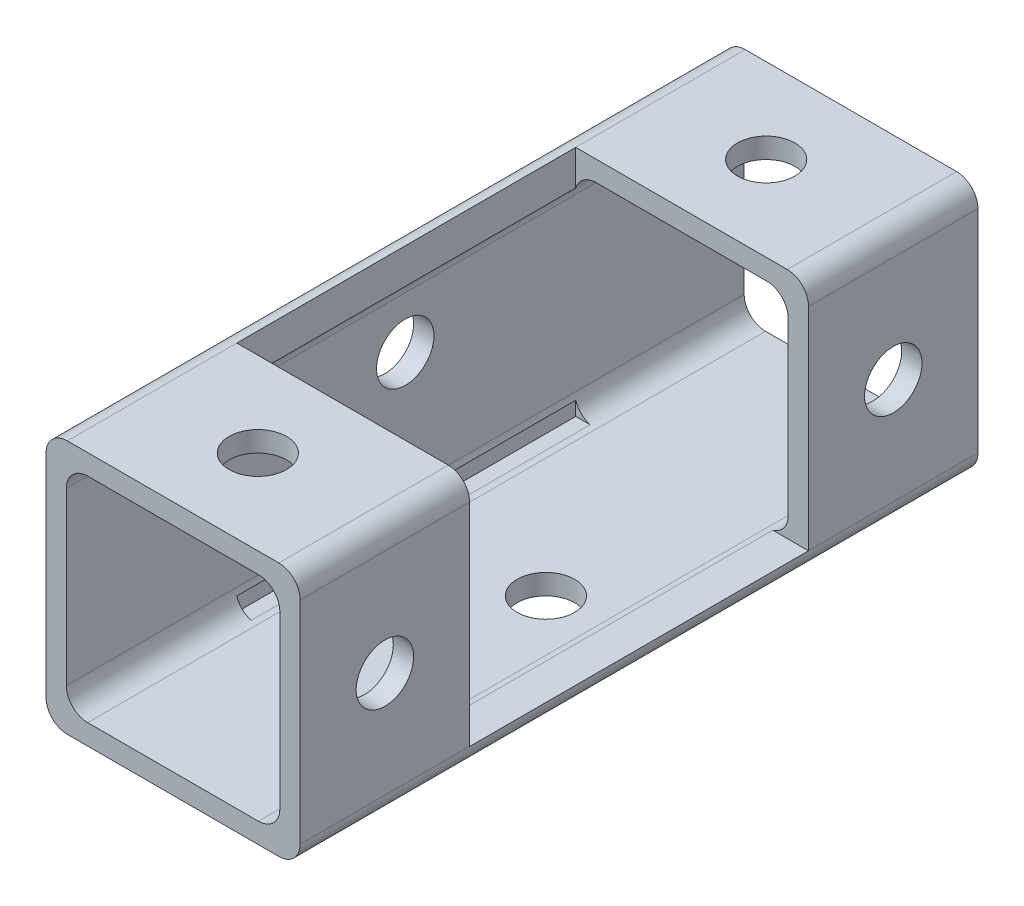
from build123d import *

# Parameters (mm, degrees)
SKETCH3_W                = 19.05
SKETCH3_H                = 19.05
SKETCH3_W_2              = 16.002
SKETCH3_H_2              = 16.002
BOSS_EXTRUDE1_DEPTH      = 25.4
BOSS_EXTRUDE1_DEPTH_BACK = 25.4
FILLET1_R                = 1.6002
SKETCH5_W                = 19.784949474
SKETCH5_H                = 25.4
CUT_EXTRUDE1_DEPTH       = 17.4625
SKETCH7_R                = 2.15265
CUT_EXTRUDE2_DEPTH       = 12.7
SKETCH6_R                = 2.15265
CUT_EXTRUDE3_DEPTH       = 2.524
SKETCH9_R                = 2.15265
CUT_EXTRUDE5_DEPTH       = 6.35
SKETCH10_R               = 2.15265
CUT_EXTRUDE6_DEPTH       = 20.05


with BuildPart() as part:
    # Sketch3 → Boss-Extrude1 (new body, two sides)
    with BuildSketch(Plane.XY) as boss_extrude1_sk:
        Rectangle(SKETCH3_W, SKETCH3_H)
        Rectangle(SKETCH3_W_2, SKETCH3_H_2, mode=Mode.SUBTRACT)
    extrude(amount=BOSS_EXTRUDE1_DEPTH)
    extrude(boss_extrude1_sk.sketch, amount=-BOSS_EXTRUDE1_DEPTH_BACK)

    # Fillet1
    fillet1_edges = [part.edges().sort_by_distance(p)[0] for p in [
        (8.001, -8.001, 0),
        (8.001, 8.001, 0),
        (-8.001, 8.001, 0),
        (-8.001, -8.001, 0),
        (9.525, -9.525, 0),
        (-9.525, -9.525, 0),
        (-9.525, 9.525, 0),
        (9.525, 9.525, 0),
    ]]
    fillet(fillet1_edges, radius=FILLET1_R)

    # Sketch5 → Cut-Extrude1 (cut)
    with BuildSketch(Plane(origin=(0, 9.525, 0), x_dir=(1, 0, 0), z_dir=(0, 1, 0))):
        with Locations((1.967674737, 0)):
            Rectangle(SKETCH5_W, SKETCH5_H)
    extrude(amount=-CUT_EXTRUDE1_DEPTH, mode=Mode.SUBTRACT)

    # Sketch7 → Cut-Extrude2 (cut)
    with BuildSketch(Plane(origin=(0, 9.525, 0), x_dir=(1, 0, 0), z_dir=(0, 1, 0))):
        with Locations((0, 19.05)):
            Circle(SKETCH7_R)
        with Locations((2.54, 0)):
            Circle(SKETCH7_R)
        with Locations((0, -19.05)):
            Circle(SKETCH7_R)
    extrude(amount=-CUT_EXTRUDE2_DEPTH, mode=Mode.SUBTRACT)

    # Sketch6 → Cut-Extrude3 (cut, through all)
    with BuildSketch(Plane(origin=(0, -8.001, 0), x_dir=(1, 0, 0), z_dir=(0, 1, 0))):
        with Locations((2.54, 0)):
            Circle(SKETCH6_R)
    extrude(amount=-CUT_EXTRUDE3_DEPTH, mode=Mode.SUBTRACT)

    # Sketch9 → Cut-Extrude5 (cut)
    with BuildSketch(Plane(origin=(9.525, 0, 0), x_dir=(0, 0, -1), z_dir=(1, 0, 0))):
        with Locations((-19.05, 0)):
            Circle(SKETCH9_R)
        with Locations((19.05, 0)):
            Circle(SKETCH9_R)
    extrude(amount=-CUT_EXTRUDE5_DEPTH, mode=Mode.SUBTRACT)

    # Sketch10 → Cut-Extrude6 (cut, through all)
    with BuildSketch(Plane(origin=(9.525, 0, 0), x_dir=(0, 0, -1), z_dir=(1, 0, 0))):
        with Locations((0, 2.54)):
            Circle(SKETCH10_R)
    extrude(amount=-CUT_EXTRUDE6_DEPTH, mode=Mode.SUBTRACT)


solid = part.part
